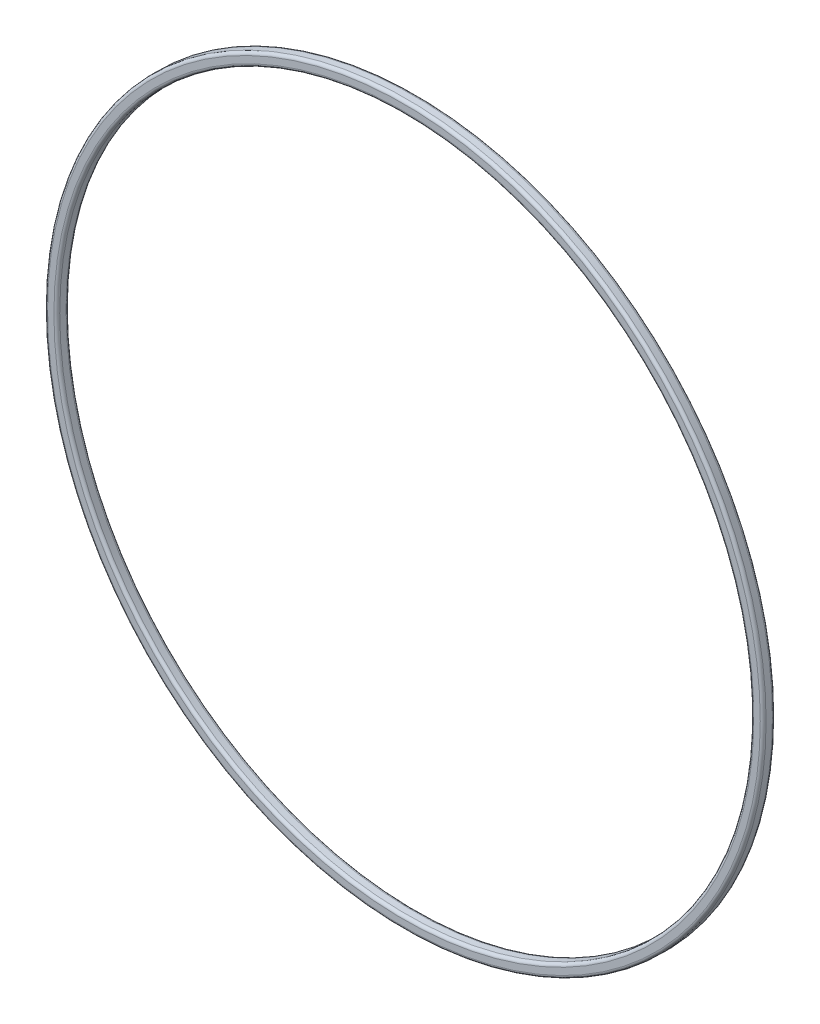
from build123d import *


with BuildPart() as part:
    # Sketch1 → Revolve1 (revolve)
    with BuildSketch(Plane(origin=(0, 0, 0), x_dir=(0, 0, -1), z_dir=(1, 0, 0))):
        with BuildLine():
            Line((-0.8255, 93.6625), (0.8255, 93.6625))
            ThreePointArc((0.8255, 93.6625), (1.364315367, 93.439315367), (1.5875, 92.9005))
            Line((1.5875, 92.9005), (1.5875, 91.2495))
            ThreePointArc((1.5875, 91.2495), (1.364315367, 90.710684633), (0.8255, 90.4875))
            Line((0.8255, 90.4875), (-0.8255, 90.4875))
            ThreePointArc((-0.8255, 90.4875), (-1.364315367, 90.710684633), (-1.5875, 91.2495))
            Line((-1.5875, 91.2495), (-1.5875, 92.9005))
            ThreePointArc((-1.5875, 92.9005), (-1.364315367, 93.439315367), (-0.8255, 93.6625))
        make_face()
    revolve(axis=Axis((0, 0, 0), (0, 0, 1)))


solid = part.part
